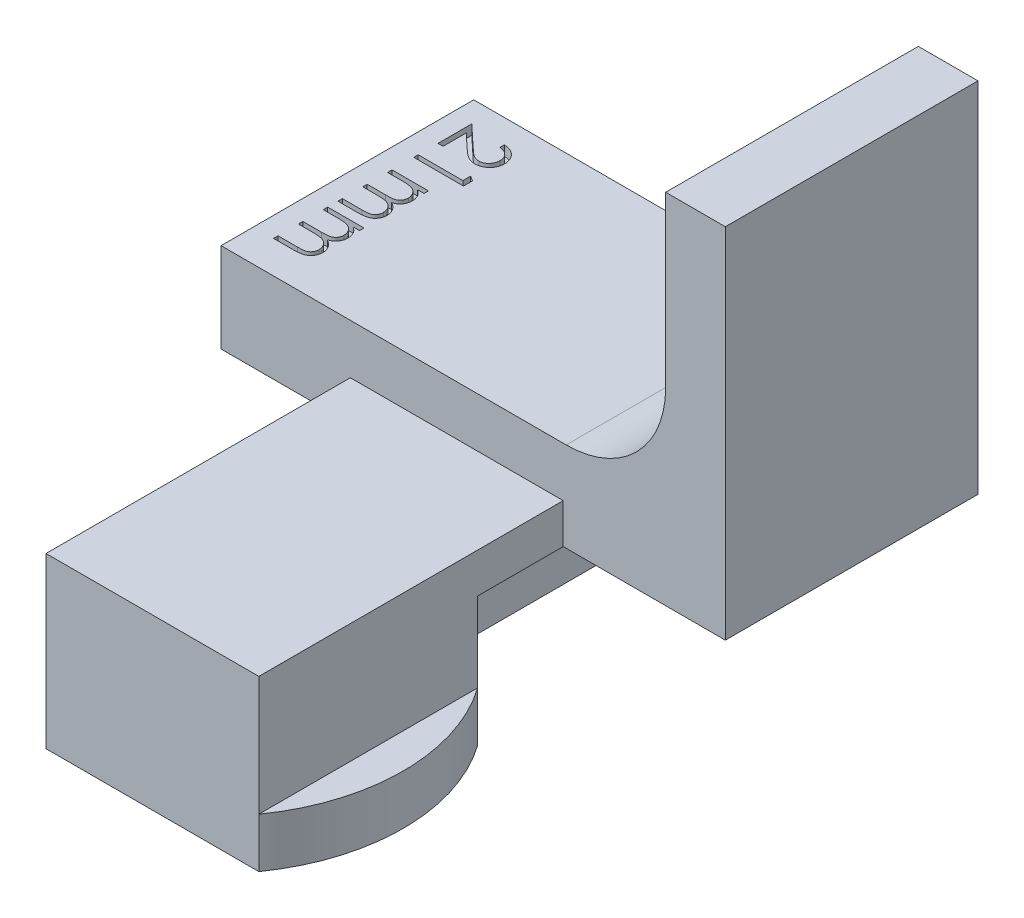
from build123d import *

# Parameters (mm, degrees)
BOSS_EXTRUDE1_DEPTH = 12.7
FILLET1_R           = 5
BOSS_EXTRUDE2_START = -12.7
BOSS_EXTRUDE2_DEPTH = 28
SKETCH4_W           = 14.2
SKETCH4_H           = 4.5
CUT_EXTRUDE2_DEPTH  = 17
SKETCH2_OUTSIDE_W   = 36.354
SKETCH2_OUTSIDE_H   = 39.004
CUT_EXTRUDE1_DEPTH  = 10
CUT_EXTRUDE3_DEPTH  = 0.5
SKETCH6_W           = 17
SKETCH6_H           = 2
CUT_EXTRUDE4_DEPTH  = 0.35
CUT_EXTRUDE5_START  = -10.7
SKETCH6_2_W         = 17
SKETCH6_2_H         = 2
CUT_EXTRUDE5_DEPTH  = 0.35


with BuildPart() as part:
    # Sketch1 → Boss-Extrude1 (new body)
    with BuildSketch(Plane.XY):
        Polygon((0, 0), (0, -4), (-1.75, -4), (-1.75, -6.5), (12.45, -6.5), (12.45, -4), (10.7, -4), (10.7, 0), (18.85, 0), (18.85, 18), (15.85, 18), (15.85, 4.5), (-6.5, 4.5), (-6.5, 0), align=None)
    extrude(amount=BOSS_EXTRUDE1_DEPTH)

    # Fillet1
    fillet1_edges = [part.edges().sort_by_distance(p)[0] for p in [
        (15.85, 4.5, 6.35),
    ]]
    fillet(fillet1_edges, radius=FILLET1_R)

    # Sketch3 → Boss-Extrude2 (add)
    with BuildSketch(Plane.XY.offset(12.7).offset(BOSS_EXTRUDE2_START)):
        Polygon((0, 0), (0, 2), (10.7, 2), (10.7, 0), (10.7, -4), (12.45, -4), (12.45, -6.5), (-1.75, -6.5), (-1.75, -4), (0, -4), align=None)
    extrude(amount=BOSS_EXTRUDE2_DEPTH)

    # Sketch4 → Cut-Extrude2 (cut)
    with BuildSketch(Plane(origin=(0, 0, 0), x_dir=(-1, 0, 0), z_dir=(0, 0, -1))):
        with Locations((-5.35, -4.25)):
            Rectangle(SKETCH4_W, SKETCH4_H)
    extrude(amount=-CUT_EXTRUDE2_DEPTH, mode=Mode.SUBTRACT)

    # Sketch2 outside → Cut-Extrude1 (cut)
    with BuildSketch(Plane(origin=(0, -4, 0), x_dir=(1, 0, 0), z_dir=(0, 1, 0))):
        with Locations((6.175, -14)):
            Rectangle(SKETCH2_OUTSIDE_W, SKETCH2_OUTSIDE_H)
        with BuildLine():
            Line((0, -28), (10.7, -28))
            ThreePointArc((10.7, -28), (12.45, -22.5), (10.7, -17))
            Line((10.7, -17), (0, -17))
            ThreePointArc((0, -17), (-1.75, -22.5), (0, -28))
        make_face(mode=Mode.SUBTRACT)
    extrude(amount=-CUT_EXTRUDE1_DEPTH, mode=Mode.SUBTRACT)

    # Sketch5 → Cut-Extrude3 (cut)
    with BuildSketch(Plane(origin=(0, 4.5, 0), x_dir=(1, 0, 0), z_dir=(0, 1, 0))):
        with BuildLine():
            Line((-3.769230769, -1.416666667), (-3.769230769, -1.192307692))
            add(Edge.make_bspline(
                [(-3.769230769, -1.192307692), (-3.739465703, -1.193769696), (-3.681007904, -1.196641031), (-3.595778619, -1.210093331), (-3.514303391, -1.229324068), (-3.437280723, -1.25657851), (-3.363790512, -1.290235363), (-3.294808625, -1.331441091), (-3.229650424, -1.379317255), (-3.169549571, -1.433776024), (-3.114609876, -1.492868808), (-3.06666458, -1.556241548), (-3.026618971, -1.623242893), (-2.992959714, -1.693291702), (-2.967725032, -1.76719811), (-2.948993088, -1.844255655), (-2.93772487, -1.924812628), (-2.936513511, -1.979698296), (-2.935897436, -2.007612179)],
                knots=[0, 0, 0, 0, 8.9345e-05, 0.000175471, 0.000258432, 0.000340159, 0.000420153, 0.000500544, 0.000580775, 0.000662333, 0.000743489, 0.000822516, 0.000900244, 0.000977304, 0.001055226, 0.001134057, 0.001214939, 0.001298647, 0.001298647, 0.001298647, 0.001298647], degree=3))
            add(Edge.make_bspline(
                [(-2.935897436, -2.007612179), (-2.936539191, -2.03502509), (-2.937800215, -2.088890479), (-2.948629522, -2.167506203), (-2.965590659, -2.242347128), (-2.989387385, -2.313266961), (-3.021376262, -2.379699864), (-3.059803075, -2.442144896), (-3.104245812, -2.501345475), (-3.156569964, -2.554636035), (-3.21242881, -2.603570377), (-3.272063027, -2.645786274), (-3.333655374, -2.681938533), (-3.397675518, -2.712072591), (-3.464726252, -2.734255547), (-3.533831397, -2.751097124), (-3.605706262, -2.760616705), (-3.654353802, -2.762077722), (-3.679086538, -2.762820513)],
                knots=[0, 0, 0, 0, 8.2206e-05, 0.000161532, 0.000237582, 0.000312174, 0.000385423, 0.000458258, 0.000531878, 0.000606964, 0.000681872, 0.000754411, 0.000825787, 0.000895917, 0.000966233, 0.001037292, 0.001109039, 0.001183241, 0.001183241, 0.001183241, 0.001183241], degree=3))
            add(Edge.make_bspline(
                [(-3.679086538, -2.762820513), (-3.71390642, -2.761611039), (-3.782935144, -2.759213317), (-3.884374332, -2.738703048), (-3.982655346, -2.706669826), (-4.061753419, -2.668100285), (-4.125491628, -2.629191397), (-4.177969275, -2.594128891), (-4.234473181, -2.553082598), (-4.294814136, -2.505455099), (-4.359464783, -2.452231619), (-4.428386065, -2.392930074), (-4.500865901, -2.327127586), (-4.550369902, -2.280942943), (-4.576021635, -2.257011218)],
                knots=[0, 0, 0, 0, 0.00010437, 0.000206908, 0.000309214, 0.000413814, 0.000469985, 0.000533183, 0.000603103, 0.000679442, 0.000763763, 0.000854314, 0.000952177, 0.001057422, 0.001057422, 0.001057422, 0.001057422], degree=3))
            Line((-4.576021635, -2.257011218), (-5.243589744, -1.631510417))
            Line((-5.243589744, -1.631510417), (-5.243589744, -2.794871795))
            Line((-5.243589744, -2.794871795), (-5.5, -2.794871795))
            Line((-5.5, -2.794871795), (-5.5, -1.096153846))
            Line((-5.5, -1.096153846), (-4.465344551, -2.065705128))
            add(Edge.make_bspline(
                [(-4.465344551, -2.065705128), (-4.440704248, -2.089312433), (-4.393375267, -2.134657234), (-4.324255471, -2.198765658), (-4.260207374, -2.256437951), (-4.200947164, -2.307712368), (-4.146810791, -2.352631099), (-4.097374002, -2.391050425), (-4.053061049, -2.42314015), (-4.001004044, -2.457148572), (-3.937370093, -2.489577858), (-3.85999724, -2.518079883), (-3.780171816, -2.535334621), (-3.726244495, -2.53741506), (-3.69911859, -2.538461538)],
                knots=[0, 0, 0, 0, 0.000102371, 0.000196633, 0.000282807, 0.00036092, 0.00043171, 0.000493817, 0.000548716, 0.000595807, 0.000680247, 0.000762311, 0.000842655, 0.000923972, 0.000923972, 0.000923972, 0.000923972], degree=3))
            add(Edge.make_bspline(
                [(-3.69911859, -2.538461538), (-3.682058563, -2.538012101), (-3.648436526, -2.537126347), (-3.599173745, -2.529161064), (-3.551469794, -2.517458483), (-3.5059145, -2.49942119), (-3.461611877, -2.477750046), (-3.419908864, -2.450063563), (-3.379383905, -2.418425182), (-3.341426566, -2.381726212), (-3.30665175, -2.341437563), (-3.275849492, -2.298868859), (-3.250107098, -2.253833431), (-3.229004646, -2.206518962), (-3.21245079, -2.157057938), (-3.200980379, -2.105354542), (-3.193778604, -2.051551675), (-3.192804196, -2.014813464), (-3.192307692, -1.99609375)],
                knots=[0, 0, 0, 0, 5.1143e-05, 0.000100793, 0.000149379, 0.000198206, 0.000247478, 0.000297068, 0.000348064, 0.000401546, 0.00045516, 0.000507556, 0.000558926, 0.000610487, 0.000662748, 0.000715112, 0.000769155, 0.0008253, 0.0008253, 0.0008253, 0.0008253], degree=3))
            add(Edge.make_bspline(
                [(-3.192307692, -1.99609375), (-3.192818275, -1.976543068), (-3.193820976, -1.938148758), (-3.200839356, -1.881779251), (-3.212935551, -1.827999215), (-3.229519178, -1.776699782), (-3.250398096, -1.727831527), (-3.276905454, -1.681836316), (-3.308006308, -1.638294229), (-3.343459583, -1.597285236), (-3.383118274, -1.559604405), (-3.426783108, -1.525801638), (-3.474738119, -1.496971452), (-3.525900148, -1.471414789), (-3.581629531, -1.451860159), (-3.640575816, -1.43514505), (-3.703576488, -1.423002759), (-3.746982525, -1.418813776), (-3.769230769, -1.416666667)],
                knots=[0, 0, 0, 0, 5.8647e-05, 0.000115173, 0.000170091, 0.000223779, 0.000276715, 0.000329204, 0.000382705, 0.000437025, 0.000491578, 0.000546571, 0.000602313, 0.000659202, 0.000717819, 0.000779181, 0.000842925, 0.000909953, 0.000909953, 0.000909953, 0.000909953], degree=3))
        make_face()
        Polygon((-3, -3.550580929), (-3, -4.012820513), (-5.5, -4.012820513), (-5.5, -3.788461538), (-3.256410256, -3.788461538), (-3.256410256, -3.403846154), align=None)
        with BuildLine():
            Line((-3.673076923, -5.102564103), (-3.673076923, -5.326923077))
            Line((-3.673076923, -5.326923077), (-3.990584936, -5.326923077))
            add(Edge.make_bspline(
                [(-3.990584936, -5.326923077), (-3.962849174, -5.34716972), (-3.90979484, -5.385898498), (-3.839103141, -5.448797063), (-3.780096742, -5.512713891), (-3.748715772, -5.558420094), (-3.733673878, -5.580328526)],
                knots=[0, 0, 0, 0, 0.000102966, 0.000196958, 0.000283467, 0.000363109, 0.000363109, 0.000363109, 0.000363109], degree=3))
            add(Edge.make_bspline(
                [(-3.733673878, -5.580328526), (-3.719384332, -5.610231856), (-3.691054893, -5.66951607), (-3.662316637, -5.763386945), (-3.64465585, -5.85944028), (-3.642240584, -5.92430329), (-3.641025641, -5.95693109)],
                knots=[0, 0, 0, 0, 9.9308e-05, 0.000196881, 0.000293544, 0.000391385, 0.000391385, 0.000391385, 0.000391385], degree=3))
            add(Edge.make_bspline(
                [(-3.641025641, -5.95693109), (-3.641774259, -5.978996712), (-3.643255733, -6.022663392), (-3.652841119, -6.087378046), (-3.669609496, -6.150240939), (-3.692373764, -6.210844306), (-3.720823163, -6.267595926), (-3.753536683, -6.319722966), (-3.790488617, -6.366585325), (-3.833109774, -6.408107089), (-3.882637794, -6.445441216), (-3.940397397, -6.479783522), (-4.007688759, -6.511515734), (-4.056521976, -6.529102395), (-4.082231571, -6.538361378)],
                knots=[0, 0, 0, 0, 6.6199e-05, 0.000131004, 0.000195748, 0.000261045, 0.000324875, 0.00038587, 0.00044539, 0.00050347, 0.000563868, 0.000631031, 0.000704732, 0.000786676, 0.000786676, 0.000786676, 0.000786676], degree=3))
            add(Edge.make_bspline(
                [(-4.082231571, -6.538361378), (-4.064571271, -6.548155129), (-4.029818282, -6.567427856), (-3.980633806, -6.599789024), (-3.934628967, -6.633694597), (-3.891767192, -6.669433505), (-3.852260399, -6.706879695), (-3.815977042, -6.746209064), (-3.782764696, -6.787198937), (-3.743952279, -6.844189786), (-3.702887596, -6.918231383), (-3.666820915, -7.011609342), (-3.644996157, -7.10893871), (-3.642355706, -7.17510418), (-3.641025641, -7.208433494)],
                knots=[0, 0, 0, 0, 6.0564e-05, 0.000119181, 0.000176474, 0.000231939, 0.000286492, 0.000339652, 0.000392367, 0.000444597, 0.000546357, 0.000645594, 0.000744022, 0.000843928, 0.000843928, 0.000843928, 0.000843928], degree=3))
            add(Edge.make_bspline(
                [(-3.641025641, -7.208433494), (-3.642180799, -7.23906311), (-3.644441555, -7.299008243), (-3.662194036, -7.386277718), (-3.692678069, -7.467664722), (-3.734273524, -7.543005491), (-3.786544369, -7.610976786), (-3.848736396, -7.670059864), (-3.920409698, -7.719895838), (-3.987832547, -7.752452009), (-4.047357785, -7.774534341), (-4.098076565, -7.788149508), (-4.153899102, -7.800177862), (-4.214892146, -7.810164466), (-4.281271152, -7.817463431), (-4.352927492, -7.822871085), (-4.429916858, -7.826531138), (-4.483035072, -7.826789761), (-4.510416667, -7.826923077)],
                knots=[0, 0, 0, 0, 9.1843e-05, 0.000179747, 0.000265793, 0.000351646, 0.00043699, 0.000522005, 0.000607999, 0.000697811, 0.000745818, 0.000798306, 0.00085518, 0.000917093, 0.000983624, 0.00105545, 0.001132653, 0.001214791, 0.001214791, 0.001214791, 0.001214791], degree=3))
            Line((-4.510416667, -7.826923077), (-5.5, -7.826923077))
            Line((-5.5, -7.826923077), (-5.5, -7.602564103))
            Line((-5.5, -7.602564103), (-4.509415064, -7.602564103))
            add(Edge.make_bspline(
                [(-4.509415064, -7.602564103), (-4.486043226, -7.602508472), (-4.441126106, -7.602401558), (-4.37666007, -7.600477536), (-4.317896958, -7.596852311), (-4.264916893, -7.592613284), (-4.217596337, -7.586724846), (-4.176030302, -7.579120619), (-4.139891931, -7.571065101), (-4.09983021, -7.557682379), (-4.055638935, -7.536290165), (-4.007972189, -7.503709763), (-3.966512436, -7.462646464), (-3.930306263, -7.415180793), (-3.901462215, -7.361006762), (-3.880083749, -7.301550172), (-3.867445823, -7.237011557), (-3.866083249, -7.192297345), (-3.865384615, -7.169370994)],
                knots=[0, 0, 0, 0, 7.0114e-05, 0.000134748, 0.000193447, 0.000246723, 0.00029418, 0.00033642, 0.000373469, 0.000405143, 0.000462933, 0.000520167, 0.000577538, 0.000637235, 0.000698627, 0.000760882, 0.000826196, 0.000894922, 0.000894922, 0.000894922, 0.000894922], degree=3))
            add(Edge.make_bspline(
                [(-3.865384615, -7.169370994), (-3.866418184, -7.141041216), (-3.868466848, -7.084888039), (-3.888606496, -7.003053701), (-3.919724694, -6.924627707), (-3.964153253, -6.851718167), (-4.017610819, -6.784563992), (-4.081140155, -6.726776322), (-4.15302033, -6.679039661), (-4.219553274, -6.646715238), (-4.279317224, -6.626294332), (-4.331529618, -6.612810815), (-4.390873599, -6.60232268), (-4.456950377, -6.592486587), (-4.530214792, -6.586066782), (-4.610327936, -6.58023223), (-4.697530764, -6.577503042), (-4.757978398, -6.577121286), (-4.789362981, -6.576923077)],
                knots=[0, 0, 0, 0, 8.4849e-05, 0.00016818, 0.000251319, 0.00033712, 0.000423311, 0.000508035, 0.000593596, 0.0006814, 0.000729071, 0.000782881, 0.000842994, 0.000909781, 0.000983233, 0.001063551, 0.001150742, 0.001244898, 0.001244898, 0.001244898, 0.001244898], degree=3))
            Line((-4.789362981, -6.576923077), (-5.5, -6.576923077))
            Line((-5.5, -6.576923077), (-5.5, -6.352564103))
            Line((-5.5, -6.352564103), (-4.571013622, -6.352564103))
            add(Edge.make_bspline(
                [(-4.571013622, -6.352564103), (-4.544803812, -6.352509908), (-4.494378771, -6.352405644), (-4.42207291, -6.350460515), (-4.356287876, -6.34693718), (-4.29718885, -6.342386504), (-4.24461523, -6.337447467), (-4.198739476, -6.329631306), (-4.159370692, -6.321483736), (-4.115774829, -6.3090498), (-4.068483866, -6.287513236), (-4.017684108, -6.25475381), (-3.972914287, -6.214057471), (-3.934949709, -6.165705663), (-3.90383078, -6.111106833), (-3.881062877, -6.051037003), (-3.867930796, -5.985875666), (-3.866249348, -5.940965122), (-3.865384615, -5.91786859)],
                knots=[0, 0, 0, 0, 7.8627e-05, 0.000151271, 0.00021697, 0.000276236, 0.000329108, 0.000375296, 0.000415765, 0.000449679, 0.000511104, 0.000570834, 0.000630394, 0.000691713, 0.000754513, 0.000818227, 0.000883639, 0.000952896, 0.000952896, 0.000952896, 0.000952896], degree=3))
            add(Edge.make_bspline(
                [(-3.865384615, -5.91786859), (-3.866477801, -5.890714153), (-3.868656482, -5.836596325), (-3.888266677, -5.757094916), (-3.918983875, -5.680319438), (-3.961598025, -5.607494611), (-4.014383105, -5.540584666), (-4.076465083, -5.482006737), (-4.147071879, -5.432764324), (-4.212902559, -5.400091429), (-4.271171658, -5.379037283), (-4.320699289, -5.364983294), (-4.375763388, -5.353197643), (-4.436243472, -5.343207902), (-4.50226507, -5.335690764), (-4.573641592, -5.331193303), (-4.65059847, -5.327239971), (-4.703719911, -5.327031299), (-4.731270032, -5.326923077)],
                knots=[0, 0, 0, 0, 8.1352e-05, 0.000162132, 0.000244155, 0.000328761, 0.000414326, 0.000498997, 0.000583882, 0.000671677, 0.000718571, 0.000769613, 0.000825997, 0.000887416, 0.00095345, 0.001025239, 0.001101942, 0.00118458, 0.00118458, 0.00118458, 0.00118458], degree=3))
            Line((-4.731270032, -5.326923077), (-5.5, -5.326923077))
            Line((-5.5, -5.326923077), (-5.5, -5.102564103))
            Line((-5.5, -5.102564103), (-3.673076923, -5.102564103))
        make_face()
        with BuildLine():
            Line((-3.673076923, -8.33974359), (-3.673076923, -8.564102564))
            Line((-3.673076923, -8.564102564), (-3.990584936, -8.564102564))
            add(Edge.make_bspline(
                [(-3.990584936, -8.564102564), (-3.962849174, -8.584349207), (-3.90979484, -8.623077985), (-3.839103141, -8.68597655), (-3.780096742, -8.749893378), (-3.748715772, -8.795599581), (-3.733673878, -8.817508013)],
                knots=[0, 0, 0, 0, 0.000102966, 0.000196958, 0.000283467, 0.000363109, 0.000363109, 0.000363109, 0.000363109], degree=3))
            add(Edge.make_bspline(
                [(-3.733673878, -8.817508013), (-3.719384332, -8.847411343), (-3.691054893, -8.906695557), (-3.662316637, -9.000566432), (-3.64465585, -9.096619767), (-3.642240584, -9.161482777), (-3.641025641, -9.194110577)],
                knots=[0, 0, 0, 0, 9.9308e-05, 0.000196881, 0.000293544, 0.000391385, 0.000391385, 0.000391385, 0.000391385], degree=3))
            add(Edge.make_bspline(
                [(-3.641025641, -9.194110577), (-3.641774259, -9.216176199), (-3.643255733, -9.25984288), (-3.652841119, -9.324557533), (-3.669609496, -9.387420426), (-3.692373764, -9.448023794), (-3.720823163, -9.504775413), (-3.753536683, -9.556902453), (-3.790488617, -9.603764812), (-3.833109774, -9.645286576), (-3.882637794, -9.682620703), (-3.940397397, -9.716963009), (-4.007688759, -9.748695221), (-4.056521976, -9.766281882), (-4.082231571, -9.775540865)],
                knots=[0, 0, 0, 0, 6.6199e-05, 0.000131004, 0.000195748, 0.000261045, 0.000324875, 0.00038587, 0.00044539, 0.00050347, 0.000563868, 0.000631031, 0.000704732, 0.000786676, 0.000786676, 0.000786676, 0.000786676], degree=3))
            add(Edge.make_bspline(
                [(-4.082231571, -9.775540865), (-4.064571271, -9.785334616), (-4.029818282, -9.804607343), (-3.980633806, -9.836968511), (-3.934628967, -9.870874084), (-3.891767192, -9.906612993), (-3.852260399, -9.944059182), (-3.815977042, -9.983388551), (-3.782764696, -10.024378424), (-3.743952279, -10.081369273), (-3.702887596, -10.15541087), (-3.666820915, -10.24878883), (-3.644996157, -10.346118198), (-3.642355706, -10.412283667), (-3.641025641, -10.445612981)],
                knots=[0, 0, 0, 0, 6.0564e-05, 0.000119181, 0.000176474, 0.000231939, 0.000286492, 0.000339652, 0.000392367, 0.000444597, 0.000546357, 0.000645594, 0.000744022, 0.000843928, 0.000843928, 0.000843928, 0.000843928], degree=3))
            add(Edge.make_bspline(
                [(-3.641025641, -10.445612981), (-3.642180799, -10.476242597), (-3.644441555, -10.53618773), (-3.662194036, -10.623457206), (-3.692678069, -10.704844209), (-3.734273524, -10.780184978), (-3.786544369, -10.848156273), (-3.848736396, -10.907239351), (-3.920409698, -10.957075325), (-3.987832547, -10.989631496), (-4.047357785, -11.011713828), (-4.098076565, -11.025328995), (-4.153899102, -11.037357349), (-4.214892146, -11.047343953), (-4.281271152, -11.054642919), (-4.352927492, -11.060050572), (-4.429916858, -11.063710625), (-4.483035072, -11.063969248), (-4.510416667, -11.064102564)],
                knots=[0, 0, 0, 0, 9.1843e-05, 0.000179747, 0.000265793, 0.000351646, 0.00043699, 0.000522005, 0.000607999, 0.000697811, 0.000745818, 0.000798306, 0.00085518, 0.000917093, 0.000983624, 0.00105545, 0.001132653, 0.001214791, 0.001214791, 0.001214791, 0.001214791], degree=3))
            Line((-4.510416667, -11.064102564), (-5.5, -11.064102564))
            Line((-5.5, -11.064102564), (-5.5, -10.83974359))
            Line((-5.5, -10.83974359), (-4.509415064, -10.83974359))
            add(Edge.make_bspline(
                [(-4.509415064, -10.83974359), (-4.486043226, -10.839687959), (-4.441126106, -10.839581045), (-4.37666007, -10.837657023), (-4.317896958, -10.834031798), (-4.264916893, -10.829792772), (-4.217596337, -10.823904333), (-4.176030302, -10.816300107), (-4.139891931, -10.808244588), (-4.09983021, -10.794861866), (-4.055638935, -10.773469652), (-4.007972189, -10.74088925), (-3.966512436, -10.699825951), (-3.930306263, -10.65236028), (-3.901462215, -10.598186249), (-3.880083749, -10.53872966), (-3.867445823, -10.474191045), (-3.866083249, -10.429476832), (-3.865384615, -10.406550481)],
                knots=[0, 0, 0, 0, 7.0114e-05, 0.000134748, 0.000193447, 0.000246723, 0.00029418, 0.00033642, 0.000373469, 0.000405143, 0.000462933, 0.000520167, 0.000577538, 0.000637235, 0.000698627, 0.000760882, 0.000826196, 0.000894922, 0.000894922, 0.000894922, 0.000894922], degree=3))
            add(Edge.make_bspline(
                [(-3.865384615, -10.406550481), (-3.866418184, -10.378220703), (-3.868466848, -10.322067526), (-3.888606496, -10.240233188), (-3.919724694, -10.161807194), (-3.964153253, -10.088897654), (-4.017610819, -10.021743479), (-4.081140155, -9.96395581), (-4.15302033, -9.916219148), (-4.219553274, -9.883894726), (-4.279317224, -9.863473819), (-4.331529618, -9.849990302), (-4.390873599, -9.839502167), (-4.456950377, -9.829666074), (-4.530214792, -9.823246269), (-4.610327936, -9.817411717), (-4.697530764, -9.814682529), (-4.757978398, -9.814300773), (-4.789362981, -9.814102564)],
                knots=[0, 0, 0, 0, 8.4849e-05, 0.00016818, 0.000251319, 0.00033712, 0.000423311, 0.000508035, 0.000593596, 0.0006814, 0.000729071, 0.000782881, 0.000842994, 0.000909781, 0.000983233, 0.001063551, 0.001150742, 0.001244898, 0.001244898, 0.001244898, 0.001244898], degree=3))
            Line((-4.789362981, -9.814102564), (-5.5, -9.814102564))
            Line((-5.5, -9.814102564), (-5.5, -9.58974359))
            Line((-5.5, -9.58974359), (-4.571013622, -9.58974359))
            add(Edge.make_bspline(
                [(-4.571013622, -9.58974359), (-4.544803812, -9.589689396), (-4.494378771, -9.589585131), (-4.42207291, -9.587640002), (-4.356287876, -9.584116667), (-4.29718885, -9.579565992), (-4.24461523, -9.574626954), (-4.198739476, -9.566810793), (-4.159370692, -9.558663223), (-4.115774829, -9.546229287), (-4.068483866, -9.524692723), (-4.017684108, -9.491933297), (-3.972914287, -9.451236958), (-3.934949709, -9.40288515), (-3.90383078, -9.34828632), (-3.881062877, -9.28821649), (-3.867930796, -9.223055153), (-3.866249348, -9.178144609), (-3.865384615, -9.155048077)],
                knots=[0, 0, 0, 0, 7.8627e-05, 0.000151271, 0.00021697, 0.000276236, 0.000329108, 0.000375296, 0.000415765, 0.000449679, 0.000511104, 0.000570834, 0.000630394, 0.000691713, 0.000754513, 0.000818227, 0.000883639, 0.000952896, 0.000952896, 0.000952896, 0.000952896], degree=3))
            add(Edge.make_bspline(
                [(-3.865384615, -9.155048077), (-3.866477801, -9.12789364), (-3.868656482, -9.073775813), (-3.888266677, -8.994274403), (-3.918983875, -8.917498926), (-3.961598025, -8.844674098), (-4.014383105, -8.777764153), (-4.076465083, -8.719186224), (-4.147071879, -8.669943811), (-4.212902559, -8.637270916), (-4.271171658, -8.61621677), (-4.320699289, -8.602162781), (-4.375763388, -8.59037713), (-4.436243472, -8.580387389), (-4.50226507, -8.572870251), (-4.573641592, -8.56837279), (-4.65059847, -8.564419458), (-4.703719911, -8.564210786), (-4.731270032, -8.564102564)],
                knots=[0, 0, 0, 0, 8.1352e-05, 0.000162132, 0.000244155, 0.000328761, 0.000414326, 0.000498997, 0.000583882, 0.000671677, 0.000718571, 0.000769613, 0.000825997, 0.000887416, 0.00095345, 0.001025239, 0.001101942, 0.00118458, 0.00118458, 0.00118458, 0.00118458], degree=3))
            Line((-4.731270032, -8.564102564), (-5.5, -8.564102564))
            Line((-5.5, -8.564102564), (-5.5, -8.33974359))
            Line((-5.5, -8.33974359), (-3.673076923, -8.33974359))
        make_face()
    extrude(amount=-CUT_EXTRUDE3_DEPTH, mode=Mode.SUBTRACT)

    # Sketch6 → Cut-Extrude4 (cut)
    with BuildSketch(Plane.ZY):
        with Locations((8.5, -1)):
            Rectangle(SKETCH6_W, SKETCH6_H)
    extrude(amount=-CUT_EXTRUDE4_DEPTH, mode=Mode.SUBTRACT)

    # Sketch6_2 → Cut-Extrude5 (cut)
    with BuildSketch(Plane.ZY.offset(CUT_EXTRUDE5_START)):
        with Locations((8.5, -1)):
            Rectangle(SKETCH6_2_W, SKETCH6_2_H)
    extrude(amount=CUT_EXTRUDE5_DEPTH, mode=Mode.SUBTRACT)


solid = part.part
